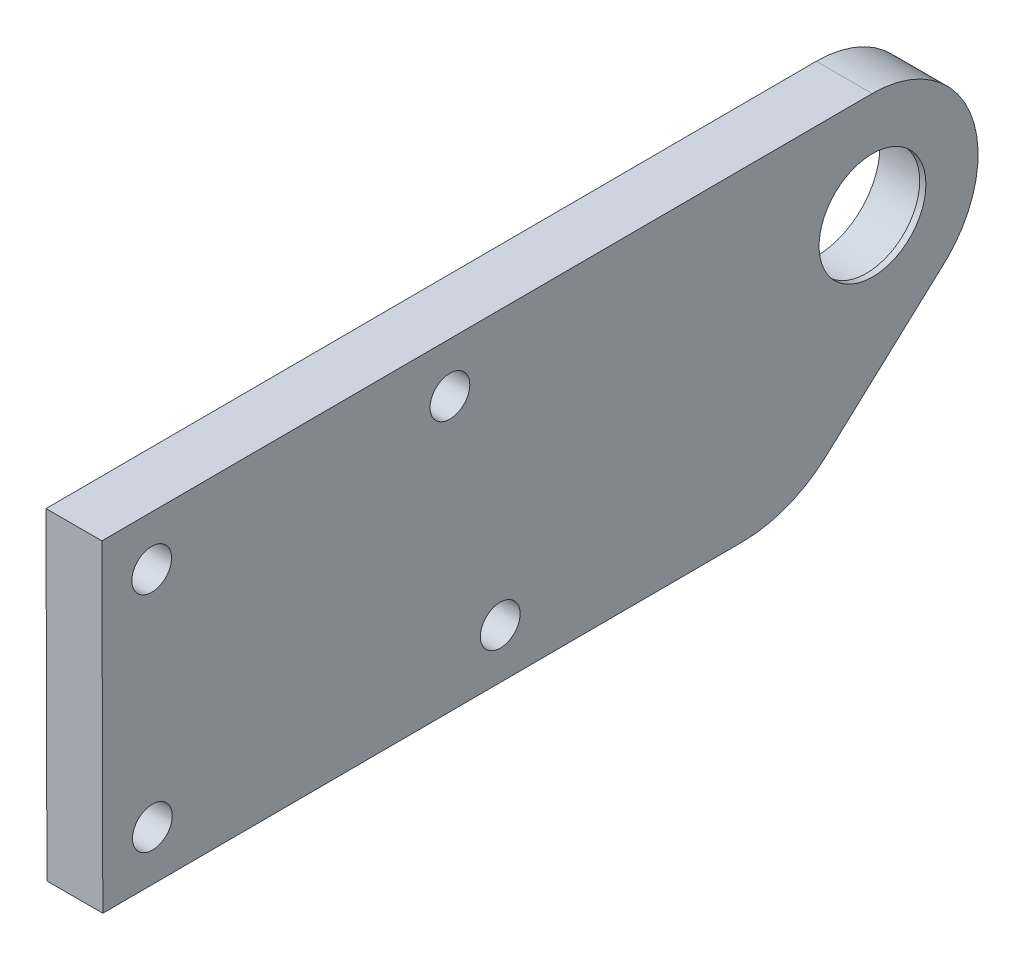
from build123d import *

# Parameters (mm, degrees)
SKETCH_1_R          = 4.3
SKETCH_1_R_2        = 1.6
EXTRUDE_1_DEPTH     = 4.5
SKETCH_2_R          = 5.1
CUT_EXTRUDE_1_DEPTH = 4


with BuildPart() as part:
    # 草图1 → 凸台-拉伸1 (new body)
    with BuildSketch(Plane(origin=(0, 0, 0), x_dir=(0, 0, -1), z_dir=(1, 0, 0))):
        with BuildLine():
            Line((-61.910667188, -17.784854846), (-10.410879829, -17.636861799))
            ThreePointArc((-10.410879829, -17.636861799), (-6.80853031, -16.954371319), (-3.69429735, -15.01936011))
            Line((-3.69429735, -15.01936011), (6.053738335, -6.112622142))
            ThreePointArc((6.053738335, -6.112622142), (7.885847556, 3.160295303), (0.014361881, 8.393204188))
            Line((0.014361881, 8.393204188), (-61.985382125, 8.215037801))
            Line((-61.985382125, 8.215037801), (-61.910667188, -17.784854846))
        make_face()
        with Locations((0.038787918, -0.106760716)):
            Circle(SKETCH_1_R, mode=Mode.SUBTRACT)
        with Locations((-57.973904035, 4.226548923)):
            Circle(SKETCH_1_R_2, mode=Mode.SUBTRACT)
        with Locations((-29.92229392, -13.692914517)):
            Circle(SKETCH_1_R_2, mode=Mode.SUBTRACT)
        with Locations((-33.97400313, 4.295516556)):
            Circle(SKETCH_1_R_2, mode=Mode.SUBTRACT)
        with Locations((-57.92217831, -13.773376756)):
            Circle(SKETCH_1_R_2, mode=Mode.SUBTRACT)
    extrude(amount=EXTRUDE_1_DEPTH)

    # 草图2 → 切除-拉伸1 (cut)
    with BuildSketch(Plane(origin=(0, 0, 0), x_dir=(0, 0, -1), z_dir=(1, 0, 0))):
        with Locations((0.038787918, -0.106760716)):
            Circle(SKETCH_2_R)
    extrude(amount=CUT_EXTRUDE_1_DEPTH, mode=Mode.SUBTRACT)


solid = part.part
